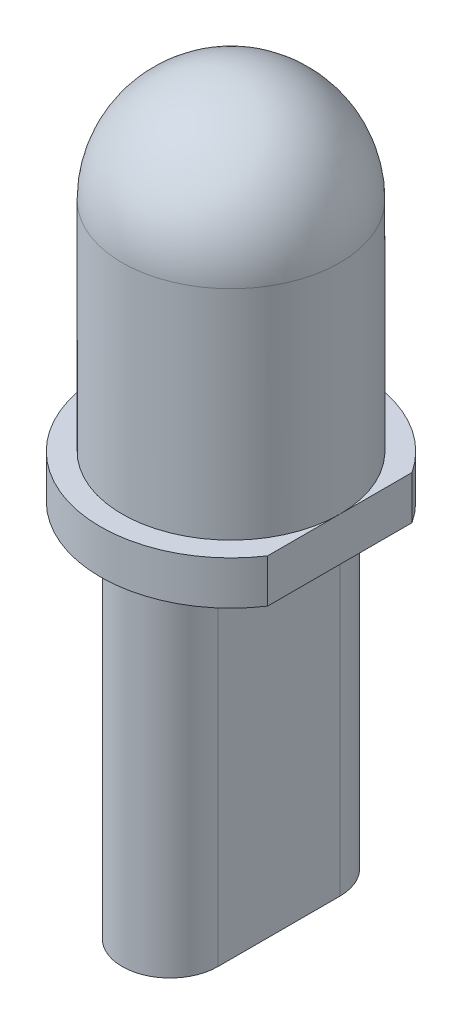
from build123d import *

# Parameters (mm, degrees)
CUT_EXTRUDE1_REACH  = 3
BOSS_EXTRUDE1_DEPTH = 8


with BuildPart() as part:
    # Sketch1 → Revolve1 (revolve)
    with BuildSketch(Plane.XY):
        with BuildLine():
            Line((0, 0), (0, 8.5))
            ThreePointArc((0, 8.5), (1.767766953, 7.767766953), (2.5, 6))
            Line((2.5, 6), (2.5, 1))
            Line((2.5, 1), (3, 1))
            Line((3, 1), (3, 0))
            Line((3, 0), (0, 0))
        make_face()
    revolve(axis=Axis((0, 0, 0), (0, 1, 0)))

    # Sketch2 → Cut-Extrude1 (cut, up to next)
    with BuildSketch(Plane(origin=(0, 1, 0), x_dir=(1, 0, 0), z_dir=(0, 1, 0)), mode=Mode.PRIVATE) as cut_extrude1_sk1:
        with BuildLine():
            Line((2.5, 1.658312395), (2.5, -1.658312395))
            ThreePointArc((2.5, -1.658312395), (3, 0), (2.5, 1.658312395))
        make_face()
    cut_extrude1_tool1 = extrude(cut_extrude1_sk1.sketch, amount=-CUT_EXTRUDE1_REACH, mode=Mode.PRIVATE) & part.part
    add(cut_extrude1_tool1.solids().sort_by_distance((2.701501, 1, 0))[0], mode=Mode.SUBTRACT)

    # Sketch3 → Boss-Extrude1 (add)
    with BuildSketch(Plane.XZ):
        with BuildLine():
            Line((1.1, 1.4), (1.1, -1.4))
            ThreePointArc((1.1, -1.4), (0, -2.5), (-1.1, -1.4))
            Line((-1.1, -1.4), (-1.1, 1.4))
            ThreePointArc((-1.1, 1.4), (0, 2.5), (1.1, 1.4))
        make_face()
    extrude(amount=BOSS_EXTRUDE1_DEPTH)


solid = part.part
